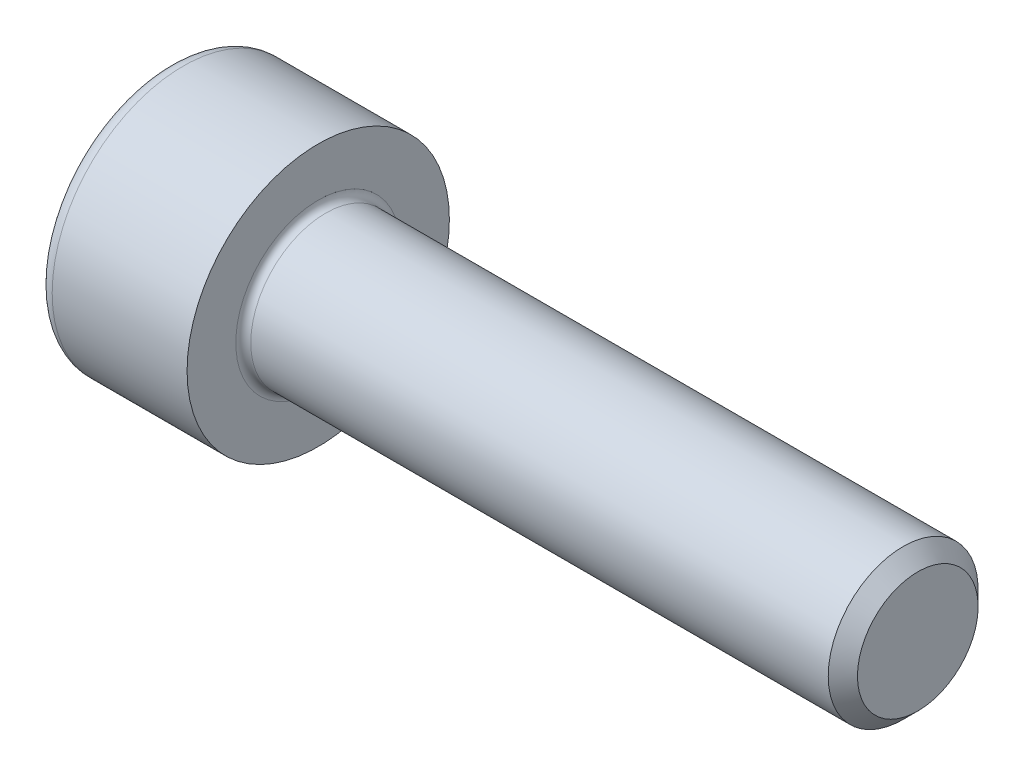
from build123d import *

# Parameters (mm, degrees)
FILLET1_R   = 0.2
FILLET2_R   = 0.4
HEX_2_DEPTH = 2


with BuildPart() as part:
    # BodySke → Base-Revolve (revolve)
    with BuildSketch(Plane.XY):
        Polygon((0, 0), (0, 3.5), (4, 3.5), (4, 2), (19.61, 2), (20, 1.61), (20, 0), align=None)
    revolve(axis=Axis((-31.75, 0, 0), (1, 0, 0)))

    # Fillet1
    fillet1_edges = [part.edges().sort_by_distance(p)[0] for p in [
        (4, -2, 0),
    ]]
    fillet(fillet1_edges, radius=FILLET1_R)

    # Fillet2
    fillet2_edges = [part.edges().sort_by_distance(p)[0] for p in [
        (0, -3.5, 0),
    ]]
    fillet(fillet2_edges, radius=FILLET2_R)

    # Sketch2 → Hex-PreBroach (revolve, cut)
    with BuildSketch(Plane.XY):
        Polygon((0, 1.51), (2, 1.51), (2.871798906, 0), (0, 0), align=None)
    revolve(axis=Axis((0, 0, 0), (1, 0, 0)), mode=Mode.SUBTRACT)

    # Sketch3 → Hex 2 (cut)
    with BuildSketch(Plane(origin=(0, 0, 0), x_dir=(0, 0.5, 0.866025404), z_dir=(-1, 0, 0))):
        Polygon((0.871798906, 1.51), (-0.871798906, 1.51), (-1.743597813, 0), (-0.871798906, -1.51), (0.871798906, -1.51), (1.743597813, 0), align=None)
    extrude(amount=-HEX_2_DEPTH, mode=Mode.SUBTRACT)


solid = part.part
